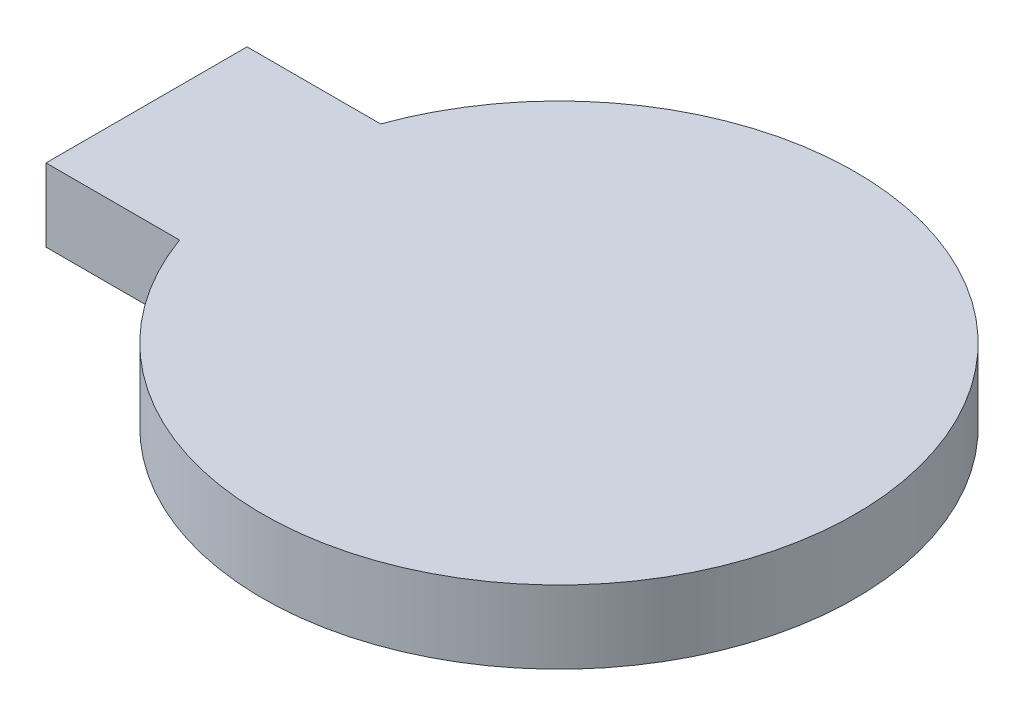
from build123d import *

# Parameters (mm, degrees)
EXTRUDE_1_DEPTH = 2.83
SKETCH_2_R      = 7.92
EXTRUDE_2_DEPTH = 1.5


with BuildPart() as part:
    # 草图1 → 凸台-拉伸1 (new body)
    with BuildSketch(Plane(origin=(0, 0, 0), x_dir=(1, 0, 0), z_dir=(0, 1, 0))):
        with BuildLine():
            Line((-16, 3.9), (-10.818502669, 3.9))
            ThreePointArc((-10.818502669, 3.9), (11.5, 0), (-10.818502669, -3.9))
            Line((-10.818502669, -3.9), (-16, -3.9))
            Line((-16, -3.9), (-16, 3.9))
        make_face()
    extrude(amount=EXTRUDE_1_DEPTH)

    # 草图2 → 凸台-拉伸2 (add)
    with BuildSketch(Plane.XZ):
        Circle(SKETCH_2_R)
    extrude(amount=EXTRUDE_2_DEPTH)


solid = part.part
